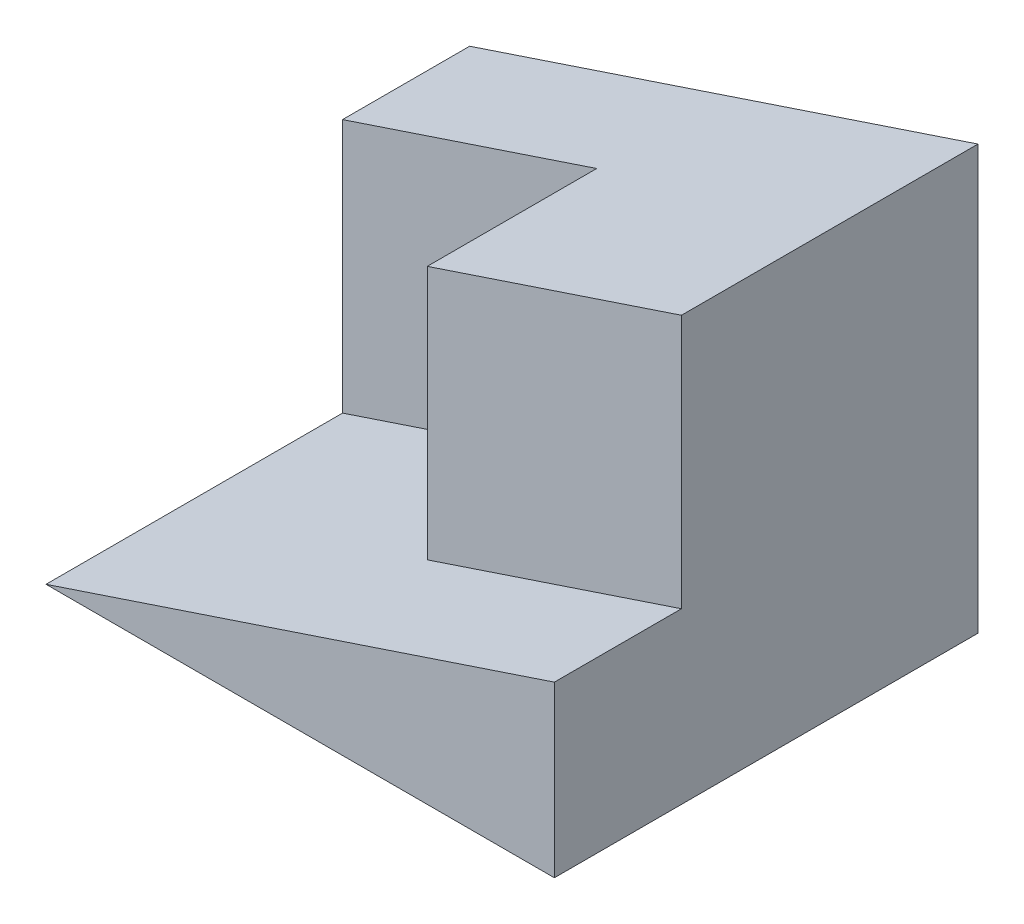
from build123d import *

# Parameters (mm, degrees)
BOSS_EXTRUDE1_DEPTH = 50
CUT_EXTRUDE1_DEPTH  = 35
CUT_EXTRUDE2_DEPTH  = 15


with BuildPart() as part:
    # Sketch1 → Boss-Extrude1 (new body)
    with BuildSketch(Plane.XY):
        Polygon((0, 30), (0, 0), (30, 10), (30, 40), align=None)
        Polygon((30, 40), (30, 10), (60, 20), (60, 50), align=None)
        Polygon((30, 10), (0, 0), (60, 0), (60, 20), align=None)
    extrude(amount=BOSS_EXTRUDE1_DEPTH)

    # Sketch2 → Cut-Extrude1 (cut)
    with BuildSketch(Plane.XY.offset(50)):
        Polygon((30, 10), (30, 40), (0, 30), (0, 0), align=None)
    extrude(amount=-CUT_EXTRUDE1_DEPTH, mode=Mode.SUBTRACT)

    # Sketch3 → Cut-Extrude2 (cut)
    with BuildSketch(Plane.XY.offset(50)):
        Polygon((30, 40), (60, 50), (60, 20), (30, 10), align=None)
    extrude(amount=-CUT_EXTRUDE2_DEPTH, mode=Mode.SUBTRACT)


solid = part.part
